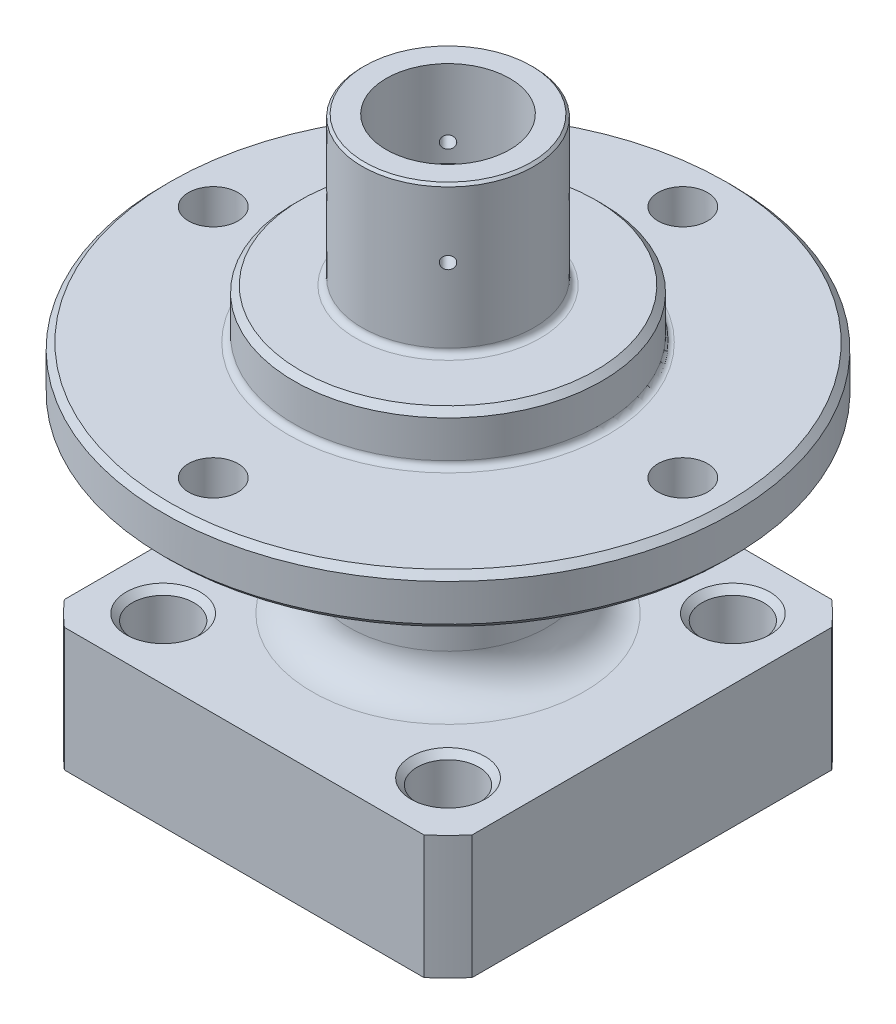
from build123d import *

# Parameters (mm, degrees)
SKETCH1_R                    = 2.5
CUT_EXTRUDE1_DEPTH           = 10
SKETCH4_R                    = 2
CUT_EXTRUDE2_DEPTH           = 4
CIRPATTERN1_COUNT            = 4
CUT_EXTRUDE3_START           = -12.136196
SKETCH5_R                    = 0.7
CUT_EXTRUDE3_DEPTH           = 12.136196
CUT_EXTRUDE4_START           = -1.975063
SKETCH6_R                    = 0.5
CUT_EXTRUDE4_DEPTH           = 1.975063
CIRPATTERN2_COUNT            = 4
CUT_EXTRUDE7_REACH           = 41.5
SKETCH8_R                    = 1
F_5_0_5_DIAMETER_HOLE1_D     = 5
F_5_0_5_DIAMETER_HOLE1_DEPTH = 6.497848452
F_5_0_5_DIAMETER_HOLE1_TIP   = 1.502151548
FILLET1_R                    = 0.5
CHAMFER1_SIZE                = 0.5
FILLET2_R                    = 3
FASE1_SIZE                   = 0.2


with BuildPart() as part:
    # Sketch3 → Revolve1 (revolve)
    with BuildSketch(Plane.XY):
        Polygon((-6.95, 45), (-5, 45), (-5, 38), (0, 38), (0, 28), (-4, 25.690598923), (-4, 0), (-22, 0), (-22, 10), (-8, 10), (-8, 25), (-23, 25), (-23, 29), (-12.45, 29), (-12.45, 33), (-6.95, 33), align=None)
    revolve(axis=Axis((0, 0, 0), (0, 1, 0)))

    # Sketch1 → Cut-Extrude1 (cut)
    with BuildSketch(Plane(origin=(0, 0, 0), x_dir=(1, 0, 0), z_dir=(0, 1, 0))):
        with BuildLine():
            ThreePointArc((14.551632211, 16.5), (0, 22), (-14.551632211, 16.5))
            Line((-14.551632211, 16.5), (14.551632211, 16.5))
        make_face()
        with BuildLine():
            Line((-16.5, -14.551632211), (-16.5, 14.551632211))
            ThreePointArc((-16.5, 14.551632211), (-22, 0), (-16.5, -14.551632211))
        make_face()
        with BuildLine():
            ThreePointArc((16.5, -14.551632211), (22, 0), (16.5, 14.551632211))
            Line((16.5, 14.551632211), (16.5, -14.551632211))
        make_face()
        with BuildLine():
            Line((14.551632211, -16.5), (-14.551632211, -16.5))
            ThreePointArc((-14.551632211, -16.5), (0, -22), (14.551632211, -16.5))
        make_face()
        with Locations((-11.525840533, 11.525840533)):
            Circle(SKETCH1_R)
        with Locations((11.525840533, 11.525840533)):
            Circle(SKETCH1_R)
        with Locations((11.525840533, -11.525840533)):
            Circle(SKETCH1_R)
        with Locations((-11.525840533, -11.525840533)):
            Circle(SKETCH1_R)
    extrude(amount=CUT_EXTRUDE1_DEPTH, mode=Mode.SUBTRACT)

    # Sketch4 → Cut-Extrude2 (cut)
    with BuildSketch(Plane(origin=(0, 29, 0), x_dir=(1, 0, 0), z_dir=(0, 1, 0))):
        with Locations((0, -19)):
            Circle(SKETCH4_R)
    cut_extrude2 = extrude(amount=-CUT_EXTRUDE2_DEPTH, mode=Mode.SUBTRACT)

    # CirPattern1: Cut-Extrude2 ×4 about axis
    cirpattern1_axis = Axis((0, 0, 0), (0, 1, 0))
    for i in range(1, CIRPATTERN1_COUNT):
        add(cut_extrude2.rotate(cirpattern1_axis, i * 360 / CIRPATTERN1_COUNT), mode=Mode.SUBTRACT)

    # Sketch5 → Cut-Extrude3 (cut)
    with BuildSketch(Plane(origin=(0, 38, 0), x_dir=(1, 0, 0), z_dir=(0, 1, 0)).offset(CUT_EXTRUDE3_START)):
        with Locations((2.121320344, -2.121320344)):
            Circle(SKETCH5_R)
    cut_extrude3 = extrude(amount=CUT_EXTRUDE3_DEPTH, mode=Mode.SUBTRACT)

    # Sketch6 → Cut-Extrude4 (cut)
    with BuildSketch(Plane(origin=(4.914392129, 0, -4.914392129), x_dir=(0, -1, 0), z_dir=(0.707106781, 0, -0.707106781)).offset(CUT_EXTRUDE4_START)):
        with Locations((-39.5, 0)):
            Circle(SKETCH6_R)
    cut_extrude4 = extrude(amount=CUT_EXTRUDE4_DEPTH, mode=Mode.SUBTRACT)

    # CirPattern2: Cut-Extrude3, Cut-Extrude4 ×4 about axis
    cirpattern2_axis = Axis((0, 0, 0), (0, 1, 0))
    for i in range(1, CIRPATTERN2_COUNT):
        add(cut_extrude3.rotate(cirpattern2_axis, i * 360 / CIRPATTERN2_COUNT), mode=Mode.SUBTRACT)
        add(cut_extrude4.rotate(cirpattern2_axis, i * 360 / CIRPATTERN2_COUNT), mode=Mode.SUBTRACT)

    # Sketch8 → Cut-Extrude7 (cut, up to next)
    with BuildSketch(Plane.ZY.offset(16.5), mode=Mode.PRIVATE) as cut_extrude7_sk1:
        with Locations((0, 5)):
            Circle(SKETCH8_R)
    cut_extrude7_tool1 = extrude(cut_extrude7_sk1.sketch, amount=-CUT_EXTRUDE7_REACH, mode=Mode.PRIVATE) & part.part
    add(cut_extrude7_tool1.solids().sort_by_distance((-16.5, 5, 0))[0], mode=Mode.SUBTRACT)

    # Ø5.0 (5) Diameter Hole1
    with Locations(Plane.ZY.offset(16.5)):
        with Locations((0, 5)):
            Hole(F_5_0_5_DIAMETER_HOLE1_D / 2, depth=F_5_0_5_DIAMETER_HOLE1_DEPTH)
            with Locations((0, 0, -(F_5_0_5_DIAMETER_HOLE1_DEPTH + F_5_0_5_DIAMETER_HOLE1_TIP / 2))):  # 118° drill point
                Cone(0, F_5_0_5_DIAMETER_HOLE1_D / 2, F_5_0_5_DIAMETER_HOLE1_TIP, mode=Mode.SUBTRACT)

    # Fillet1
    fillet1_edges = [part.edges().sort_by_distance(p)[0] for p in [
        (6.95, 33, 0),
        (12.45, 29, 0),
    ]]
    fillet(fillet1_edges, radius=FILLET1_R)

    # Chamfer1
    chamfer1_edges = [part.edges().sort_by_distance(p)[0] for p in [
        (4, 0, 0),
        (23, 25, 0),
        (23, 29, 0),
        (12.45, 33, 0),
        (-14.025840533, 10, 11.525840533),
        (-14.025840533, 0, 11.525840533),
        (9.025840533, 10, 11.525840533),
        (9.025840533, 0, 11.525840533),
        (9.025840533, 10, -11.525840533),
        (9.025840533, 0, -11.525840533),
        (-14.025840533, 10, -11.525840533),
        (-14.025840533, 0, -11.525840533),
    ]]
    chamfer(chamfer1_edges, length=CHAMFER1_SIZE)

    # Fillet2
    fillet2_edges = [part.edges().sort_by_distance(p)[0] for p in [
        (8, 10, 0),
        (8, 25, 0),
    ]]
    fillet(fillet2_edges, radius=FILLET2_R)

    # Fase1
    fase1_edges = [part.edges().sort_by_distance(p)[0] for p in [
        (6.95, 45, 0),
    ]]
    chamfer(fase1_edges, length=FASE1_SIZE)


solid = part.part
